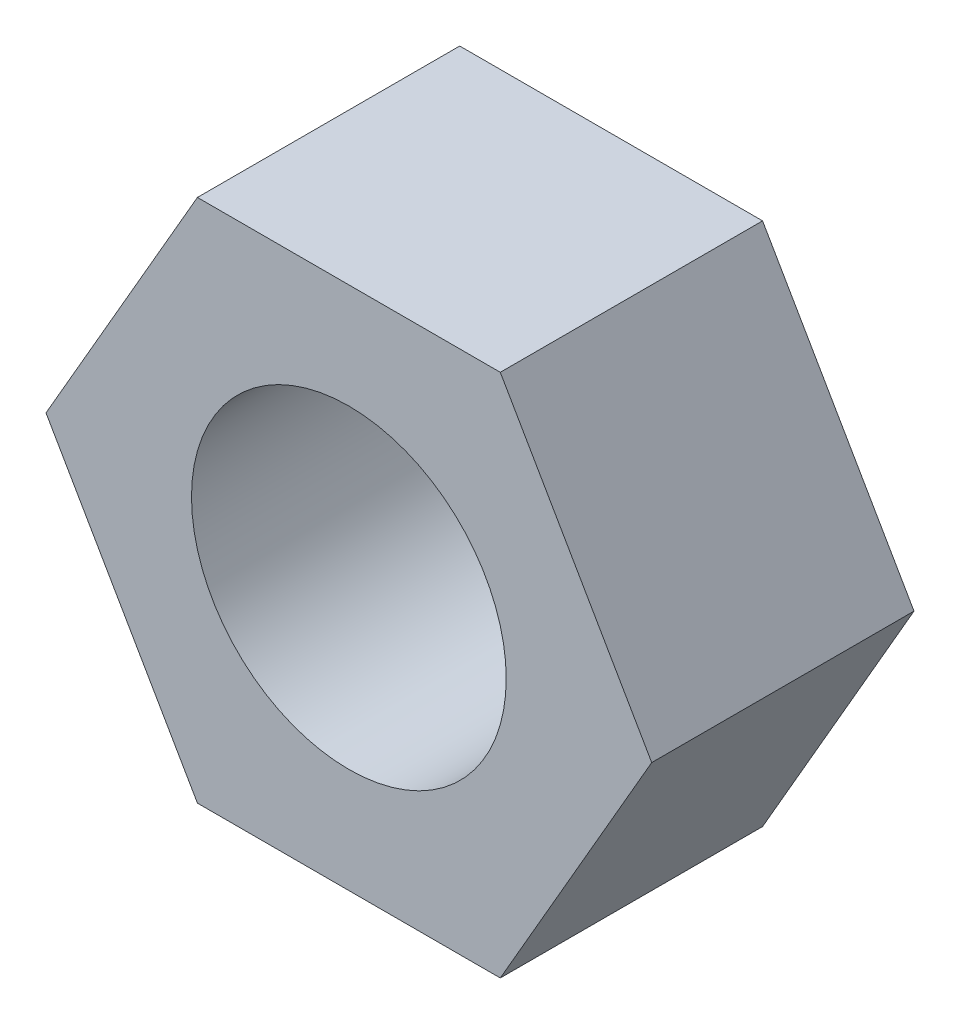
from build123d import *

# Parameters (mm, degrees)
ESBO_O1_R                = 3
RESSALTO_EXTRUS_O1_DEPTH = 5


with BuildPart() as part:
    # Esboço1 → Ressalto-extrusão1 (new body)
    with BuildSketch(Plane.XY):
        Polygon((-2.886751346, 5), (2.886751346, 5), (5.773502692, 0), (2.886751346, -5), (-2.886751346, -5), (-5.773502692, 0), align=None)
        Circle(ESBO_O1_R, mode=Mode.SUBTRACT)
    extrude(amount=RESSALTO_EXTRUS_O1_DEPTH)


solid = part.part
